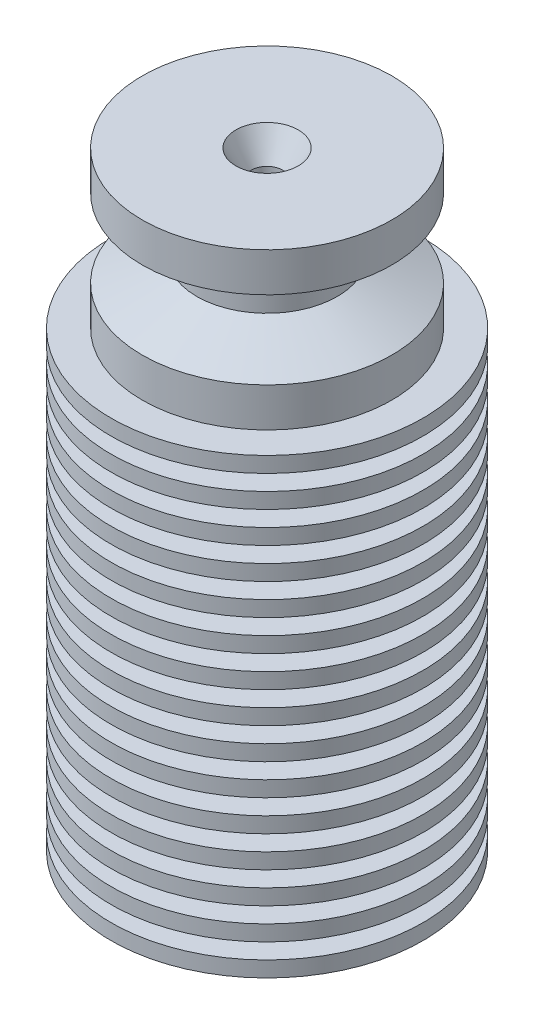
from build123d import *

# Parameters (mm, degrees)
ESQUISSE3_R                = 10
ESQUISSE3_R_2              = 2
BOSS_EXTRU_1_DEPTH         = 1
R_P_TITION_LIN_AIRE1_COUNT = 15
R_P_TITION_LIN_AIRE1_PITCH = 2
CHANFREIN1_SIZE            = 1
CHANFREIN1_SIZE2           = 1.732050808
CHANFREIN3_SIZE            = 0.5


with BuildPart() as part:
    # Esquisse2 → Révolution1 (revolve)
    with BuildSketch(Plane.XY):
        Polygon((-1, 0), (-1, -44), (-3, -44), (-3, -40), (-2, -40), (-2, -10), (-8, -10), (-8, -7.5), (-4.5, -6), (-4.5, -4), (-8, -2.5), (-8, 0), align=None)
    revolve(axis=Axis((0, 9.191211929, 0), (0, -1, 0)))

    # Esquisse3 → Boss.-Extru.1 (add)
    with BuildSketch(Plane.XZ.offset(10)):
        Circle(ESQUISSE3_R)
        Circle(ESQUISSE3_R_2, mode=Mode.SUBTRACT)
    boss_extru_1 = extrude(amount=BOSS_EXTRU_1_DEPTH)

    # Répétition linéaire1: Boss.-Extru.1 ×15
    with Locations(*[(0, -i * R_P_TITION_LIN_AIRE1_PITCH, 0) for i in range(1, R_P_TITION_LIN_AIRE1_COUNT)]):
        add(boss_extru_1)

    # Chanfrein1
    chanfrein1_edges = [part.edges().sort_by_distance(p)[0] for p in [
        (1, 0, 0),
    ]]
    chanfrein1_side = [part.faces().sort_by_distance(p)[0] for p in [
        (7.77372583, 0, 0),
    ]]
    chamfer(chanfrein1_edges, length=CHANFREIN1_SIZE, length2=CHANFREIN1_SIZE2, reference=chanfrein1_side[0])

    # Chanfrein3
    chanfrein3_edges = [part.edges().sort_by_distance(p)[0] for p in [
        (3, -40, 0),
        (3, -44, 0),
    ]]
    chamfer(chanfrein3_edges, length=CHANFREIN3_SIZE)


solid = part.part
